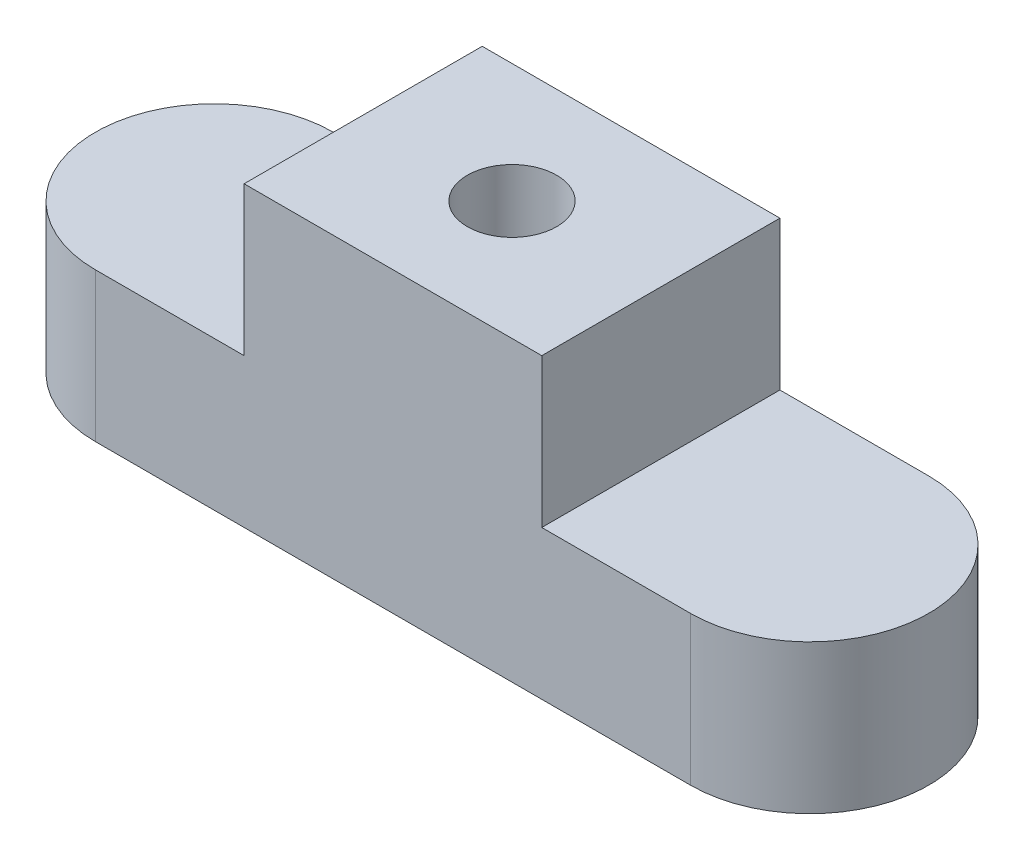
from build123d import *

# Parameters (mm, degrees)
BOSS_EXTRUDE1_DEPTH = 5
SKETCH2_W           = 10
SKETCH2_H           = 8
BOSS_EXTRUDE2_DEPTH = 5
SKETCH3_R           = 1.5
CUT_EXTRUDE1_DEPTH  = 8


with BuildPart() as part:
    # Sketch1 → Boss-Extrude1 (new body)
    with BuildSketch(Plane(origin=(0, 0, 0), x_dir=(1, 0, 0), z_dir=(0, 1, 0))):
        with BuildLine():
            Line((10, -4), (-10, -4))
            ThreePointArc((-10, -4), (-14, 0), (-10, 4))
            Line((-10, 4), (10, 4))
            ThreePointArc((10, 4), (14, 0), (10, -4))
        make_face()
    extrude(amount=BOSS_EXTRUDE1_DEPTH)

    # Sketch2 → Boss-Extrude2 (add)
    with BuildSketch(Plane(origin=(0, 5, 0), x_dir=(1, 0, 0), z_dir=(0, 1, 0))):
        Rectangle(SKETCH2_W, SKETCH2_H)
    extrude(amount=BOSS_EXTRUDE2_DEPTH)

    # Sketch3 → Cut-Extrude1 (cut)
    with BuildSketch(Plane(origin=(0, 10, 0), x_dir=(1, 0, 0), z_dir=(0, 1, 0))):
        with Locations(Location((0, 0, 0), (0, 0, 270))):  # turned: the seam where the file's is
            Circle(SKETCH3_R)
    extrude(amount=-CUT_EXTRUDE1_DEPTH, mode=Mode.SUBTRACT)


solid = part.part
